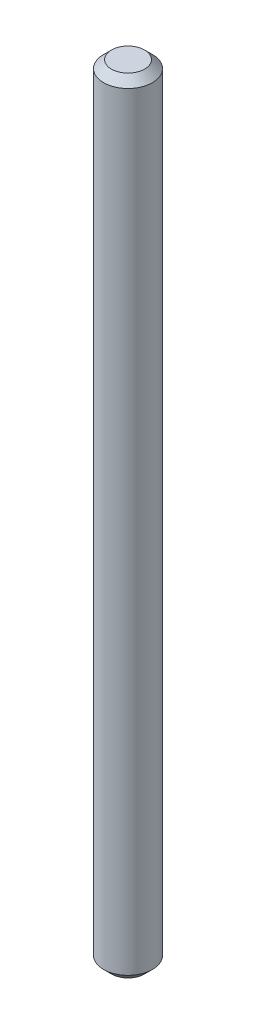
from build123d import *


with BuildPart() as part:
    # Sketch1 → Revolve1 (revolve)
    with BuildSketch(Plane.XY):
        Polygon((1.07569, 50.8), (0, 50.8), (0, 0), (1.07569, 0), (1.58369, 0.508), (1.58369, 50.292), align=None)
    revolve(axis=Axis((0, 50.8, 0), (0, -1, 0)))


solid = part.part
